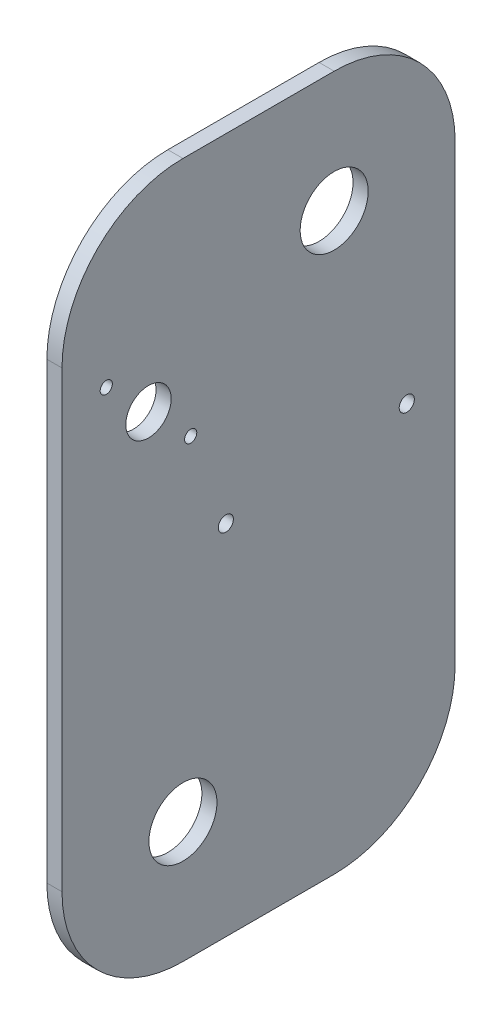
from build123d import *

# Parameters (mm, degrees)
SKETCH1_W           = 165.1
SKETCH1_H           = 292.1
BOSS_EXTRUDE1_DEPTH = 3.175
FILLET1_R           = 50.8
SKETCH2_R           = 14.2875
CUT_EXTRUDE1_DEPTH  = 7.35
SKETCH4_R           = 3.175
CUT_EXTRUDE3_DEPTH  = 7.35
SKETCH5_R           = 9.525
SKETCH5_R_2         = 2.5527
CUT_EXTRUDE4_DEPTH  = 7.35


with BuildPart() as part:
    # Sketch1 → Boss-Extrude1 (new body, symmetric)
    with BuildSketch(Plane(origin=(0, 0, 0), x_dir=(0, 0, -1), z_dir=(1, 0, 0))):
        Rectangle(SKETCH1_W, SKETCH1_H)
    extrude(amount=BOSS_EXTRUDE1_DEPTH, both=True)

    # Fillet1
    fillet1_edges = [part.edges().sort_by_distance(p)[0] for p in [
        (0, -146.05, -82.55),
        (0, -146.05, 82.55),
        (0, 146.05, 82.55),
        (0, 146.05, -82.55),
    ]]
    fillet(fillet1_edges, radius=FILLET1_R)

    # Sketch2 → Cut-Extrude1 (cut, through all)
    with BuildSketch(Plane.ZY.offset(3.175)):
        with Locations((31.75, -95.25)):
            Circle(SKETCH2_R)
        with Locations((-31.75, 95.25)):
            Circle(SKETCH2_R)
    extrude(amount=-CUT_EXTRUDE1_DEPTH, mode=Mode.SUBTRACT)

    # Sketch4 → Cut-Extrude3 (cut, through all)
    with BuildSketch(Plane(origin=(3.175, 0, 0), x_dir=(0, 0, -1), z_dir=(1, 0, 0))):
        with Locations((62.241799111, 9.91138566)):
            Circle(SKETCH4_R)
        with Locations((-13.750490704, 4.288940581)):
            Circle(SKETCH4_R)
    extrude(amount=-CUT_EXTRUDE3_DEPTH, mode=Mode.SUBTRACT)

    # Sketch5 → Cut-Extrude4 (cut, through all)
    with BuildSketch(Plane.ZY.offset(3.175)):
        with Locations((46.230164374, 61.162830951)):
            Circle(SKETCH5_R)
        with Locations((63.959364374, 78.892030951)):
            Circle(SKETCH5_R_2)
        with Locations((28.500964374, 43.433630951)):
            Circle(SKETCH5_R_2)
    extrude(amount=-CUT_EXTRUDE4_DEPTH, mode=Mode.SUBTRACT)


solid = part.part
